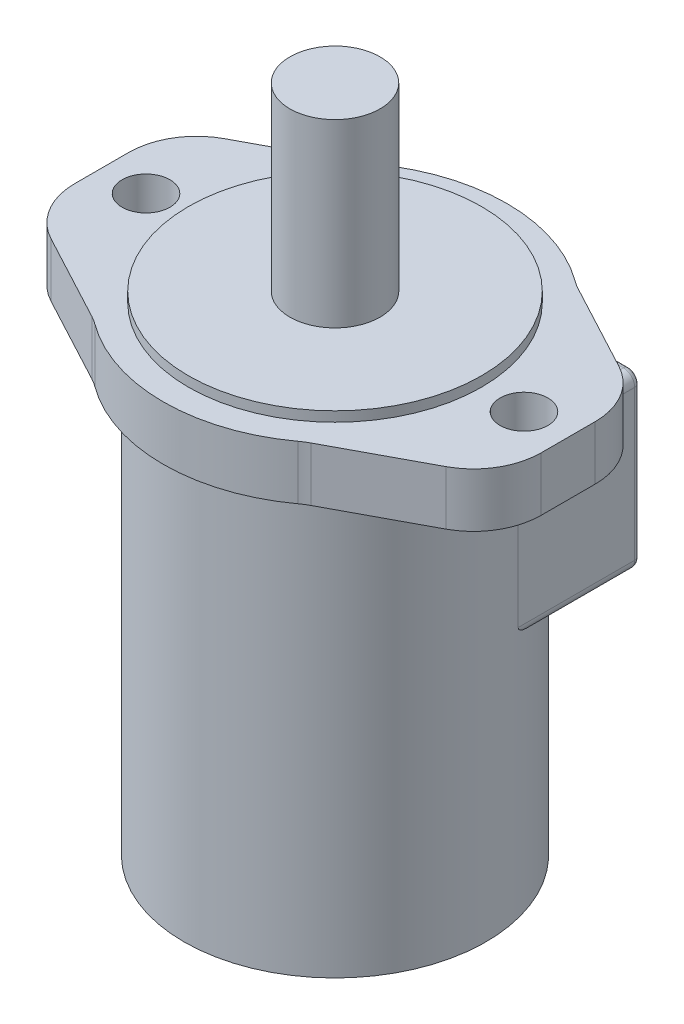
from build123d import *

# Parameters (mm, degrees)
SKETCH1_R                    = 41.275
BOSS_EXTRUDE1_DEPTH          = 2.794
SKETCH2_R                    = 42.545
BOSS_EXTRUDE2_DEPTH          = 134.62
BOSS_EXTRUDE3_DEPTH          = 4.7625
CHAMFER1_SIZE                = 0.79375
CIRPATTERN1_COUNT            = 7
CHAMFER1_OF_CIRPATTERN1_SIZE = 0.79375
SKETCH4_R                    = 3.175
CUT_EXTRUDE1_DEPTH           = 9.525
SKETCH5_R                    = 6.731
BOSS_EXTRUDE4_DEPTH          = 15.24
FILLET1_R                    = 19.05
SKETCH6_W                    = 82.55
SKETCH6_H                    = 48.514
SKETCH6_R                    = 6.35
BOSS_EXTRUDE5_DEPTH          = 44.704
FILLET2_R                    = 3.175
FILLET3_R                    = 1.5875
SKETCH7_R                    = 12.7
BOSS_EXTRUDE6_DEPTH          = 50.8
F_7_16_20_TAPPED_HOLE1_D     = 9.92124
F_7_16_20_TAPPED_HOLE1_DEPTH = 28.702
F_7_16_20_TAPPED_HOLE1_TIP   = 2.980641204


with BuildPart() as part:
    # Sketch1 → Boss-Extrude1 (new body)
    with BuildSketch(Plane(origin=(0, 0, 0), x_dir=(1, 0, 0), z_dir=(0, 1, 0))):
        Circle(SKETCH1_R)
    extrude(amount=BOSS_EXTRUDE1_DEPTH)

    # Sketch2 → Boss-Extrude2 (add)
    with BuildSketch(Plane(origin=(0, 0, 0), x_dir=(1, 0, 0), z_dir=(0, 1, 0))):
        Circle(SKETCH2_R)
    extrude(amount=-BOSS_EXTRUDE2_DEPTH)

    # Sketch3 → Boss-Extrude3 (add)
    with BuildSketch(Plane.XZ.offset(134.62)):
        Polygon((2.749630657, -36.675591008), (5.499261314, -31.913091008), (2.749630657, -27.150591008), (-2.749630657, -27.150591008), (-5.499261314, -31.913091008), (-2.749630657, -36.675591008), align=None)
    boss_extrude3 = extrude(amount=BOSS_EXTRUDE3_DEPTH)

    # Chamfer1
    chamfer1_edges = [part.edges().sort_by_distance(p)[0] for p in [
        (-4.124445986, -139.3825, -34.294341008),
        (-4.124445986, -139.3825, -29.531841008),
        (0, -139.3825, -27.150591008),
        (4.124445986, -139.3825, -29.531841008),
        (4.124445986, -139.3825, -34.294341008),
        (0, -139.3825, -36.675591008),
    ]]
    chamfer(chamfer1_edges, length=CHAMFER1_SIZE)

    # CirPattern1: Boss-Extrude3 ×7 about axis
    cirpattern1_axis = Axis((0, -146.491325, 0), (0, 1, 0))
    for i in range(1, CIRPATTERN1_COUNT):
        add(boss_extrude3.rotate(cirpattern1_axis, i * 360 / CIRPATTERN1_COUNT))

    # Chamfer1 of CirPattern1
    chamfer1_of_cirpattern1_edges = [part.edges().sort_by_distance(p)[0] for p in [
        (-29.383945481, -139.3825, -18.15755016),
        (-25.660473045, -139.3825, -15.188179979),
        (-21.227186817, -139.3825, -16.928116608),
        (-20.517373025, -139.3825, -21.637423418),
        (-24.24084546, -139.3825, -24.606793599),
        (-28.674131688, -139.3825, -22.86685697),
        (-32.516734705, -139.3825, 11.652246304),
        (-27.873640524, -139.3825, 10.592490356),
        (-26.469869006, -139.3825, 6.041574868),
        (-29.709191669, -139.3825, 2.550415329),
        (-34.352285851, -139.3825, 3.610171277),
        (-35.756057369, -139.3825, 8.161086764),
        (-11.163759477, -139.3825, 32.687663639),
        (-9.097388169, -139.3825, 28.396799406),
        (-11.780199946, -139.3825, 24.461837243),
        (-16.52938303, -139.3825, 24.817739314),
        (-18.595754337, -139.3825, 29.108603547),
        (-15.912942561, -139.3825, 33.04356571),
        (18.595754337, -139.3825, 29.108603547),
        (16.52938303, -139.3825, 24.817739314),
        (11.780199946, -139.3825, 24.461837243),
        (9.097388169, -139.3825, 28.396799406),
        (11.163759477, -139.3825, 32.687663639),
        (15.912942561, -139.3825, 33.04356571),
        (34.352285851, -139.3825, 3.610171277),
        (29.709191669, -139.3825, 2.550415329),
        (26.469869006, -139.3825, 6.041574868),
        (27.873640524, -139.3825, 10.592490356),
        (32.516734705, -139.3825, 11.652246304),
        (35.756057369, -139.3825, 8.161086764),
        (24.24084546, -139.3825, -24.606793599),
        (20.517373025, -139.3825, -21.637423418),
        (21.227186817, -139.3825, -16.928116608),
        (25.660473045, -139.3825, -15.188179979),
        (29.383945481, -139.3825, -18.15755016),
        (28.674131688, -139.3825, -22.86685697),
    ]]
    chamfer(chamfer1_of_cirpattern1_edges, length=CHAMFER1_OF_CIRPATTERN1_SIZE)

    # Sketch4 → Cut-Extrude1 (cut)
    with BuildSketch(Plane.XZ.offset(134.62)):
        Circle(SKETCH4_R)
    extrude(amount=-CUT_EXTRUDE1_DEPTH, mode=Mode.SUBTRACT)

    # Sketch5 → Boss-Extrude4 (add)
    with BuildSketch(Plane(origin=(0, 0, 0), x_dir=(1, 0, 0), z_dir=(0, 1, 0))):
        with BuildLine():
            Line((-65.659, 19.006724542), (-65.659, -19.006724542))
            Line((-65.659, -19.006724542), (-29.591473914, -38.283762101))
            ThreePointArc((-29.591473914, -38.283762101), (0, -48.387), (29.591473914, -38.283762101))
            Line((29.591473914, -38.283762101), (65.659, -19.006724542))
            Line((65.659, -19.006724542), (65.659, 19.006724542))
            Line((65.659, 19.006724542), (29.591473914, 38.283762101))
            ThreePointArc((29.591473914, 38.283762101), (0, 48.387), (-29.591473914, 38.283762101))
            Line((-29.591473914, 38.283762101), (-65.659, 19.006724542))
        make_face()
        with Locations((-53.213, 0)):
            Circle(SKETCH5_R, mode=Mode.SUBTRACT)
        with Locations((53.213, 0)):
            Circle(SKETCH5_R, mode=Mode.SUBTRACT)
    extrude(amount=-BOSS_EXTRUDE4_DEPTH)

    # Fillet1
    fillet1_edges = [part.edges().sort_by_distance(p)[0] for p in [
        (-29.591473914, -7.62, 38.283762101),
        (29.591473914, -7.62, 38.283762101),
        (65.659, -7.62, 19.006724542),
        (65.659, -7.62, -19.006724542),
        (29.591473914, -7.62, -38.283762101),
        (-29.591473914, -7.62, -38.283762101),
        (-65.659, -7.62, 19.006724542),
        (-65.659, -7.62, -19.006724542),
    ]]
    fillet(fillet1_edges, radius=FILLET1_R)

    # Sketch6 → Boss-Extrude5 (add)
    with BuildSketch(Plane.XY):
        with Locations((0, -42.672)):
            Rectangle(SKETCH6_W, SKETCH6_H)
        with Locations((22.86, -42.672)):
            Circle(SKETCH6_R, mode=Mode.SUBTRACT)
        with Locations((-22.86, -42.672)):
            Circle(SKETCH6_R, mode=Mode.SUBTRACT)
    extrude(amount=-BOSS_EXTRUDE5_DEPTH)

    # Fillet2
    fillet2_edges = [part.edges().sort_by_distance(p)[0] for p in [
        (41.275, -18.415, -27.510764387),
        (-41.275, -18.415, -27.510764387),
        (-41.275, -66.929, -27.510764387),
        (41.275, -66.929, -27.510764387),
    ]]
    fillet(fillet2_edges, radius=FILLET2_R)

    # Fillet3
    fillet3_edges = [part.edges().sort_by_distance(p)[0] for p in [
        (40.34506403, -65.99906403, -44.704),
        (0, -66.929, -44.704),
        (-40.34506403, -65.99906403, -44.704),
        (-41.275, -42.672, -44.704),
        (-40.34506403, -19.34493597, -44.704),
        (0, -18.415, -44.704),
        (40.34506403, -19.34493597, -44.704),
        (41.275, -42.672, -44.704),
    ]]
    fillet(fillet3_edges, radius=FILLET3_R)

    # Sketch7 → Boss-Extrude6 (add)
    with BuildSketch(Plane(origin=(0, 2.794, 0), x_dir=(-1, 0, 0), z_dir=(0, 1, 0))):
        Circle(SKETCH7_R)
    extrude(amount=BOSS_EXTRUDE6_DEPTH)

    # Sketch8 → 1_2 NPT Tapped Hole1 (revolve, cut)
    with BuildSketch(Plane(origin=(22.86, -42.672, -44.704), x_dir=(0, 1, 0), z_dir=(1, 0, 0))):
        Polygon((0, 0), (0, 28.478543693), (8.9281, 23.114), (8.9281, 13.462), (9.479726792, 13.462), (9.8827971, 0), align=None)
    revolve(axis=Axis((22.86, -42.672, -51.054), (0, 0, 1)), mode=Mode.SUBTRACT)

    # Sketch10 → 1_2 NPT Tapped Hole2 (revolve, cut)
    with BuildSketch(Plane(origin=(-22.86, -42.672, -44.704), x_dir=(0, 1, 0), z_dir=(1, 0, 0))):
        Polygon((0, 0), (0, 28.478543693), (8.9281, 23.114), (8.9281, 13.462), (9.479726792, 13.462), (9.8827971, 0), align=None)
    revolve(axis=Axis((-22.86, -42.672, -51.054), (0, 0, 1)), mode=Mode.SUBTRACT)

    # 7_16-20 Tapped Hole1
    with Locations(Plane.XZ.offset(134.62)):
        with Locations((0, 0)):
            Hole(F_7_16_20_TAPPED_HOLE1_D / 2, depth=F_7_16_20_TAPPED_HOLE1_DEPTH)
            with Locations((0, 0, -(F_7_16_20_TAPPED_HOLE1_DEPTH + F_7_16_20_TAPPED_HOLE1_TIP / 2))):  # 118° drill point
                Cone(0, F_7_16_20_TAPPED_HOLE1_D / 2, F_7_16_20_TAPPED_HOLE1_TIP, mode=Mode.SUBTRACT)


solid = part.part
